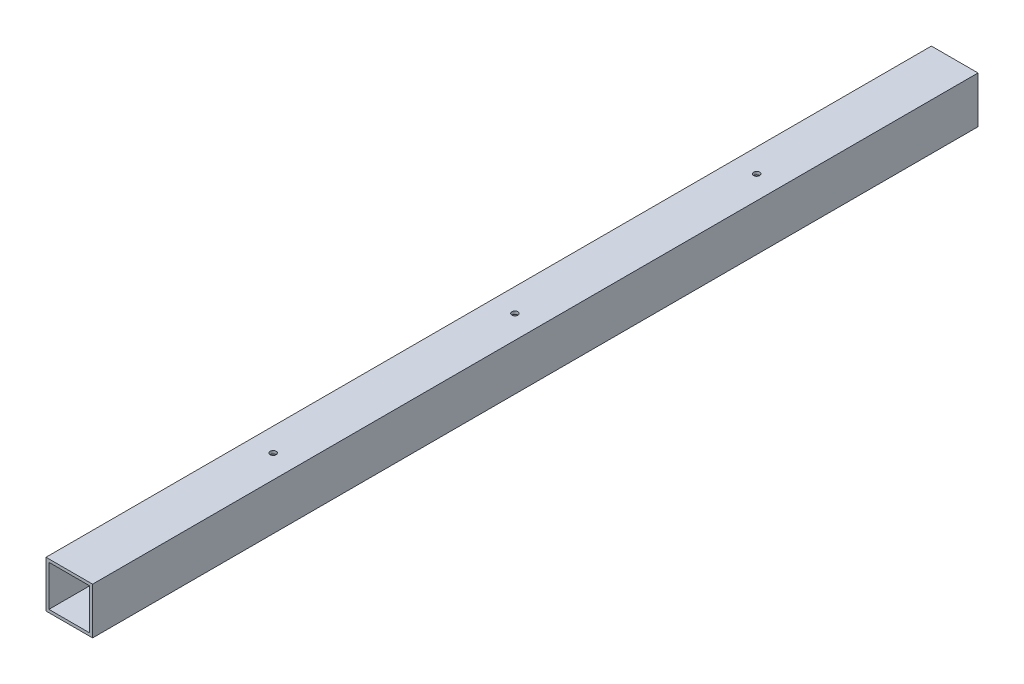
from build123d import *

# Parameters (mm, degrees)
SKETCH1_W           = 50.8
SKETCH1_H           = 50.8
SKETCH1_W_2         = 44.45
SKETCH1_H_2         = 44.45
BOSS_EXTRUDE1_DEPTH = 965.2
SKETCH2_R           = 3.302
CUT_EXTRUDE1_DEPTH  = 51.8


with BuildPart() as part:
    # Sketch1 → Boss-Extrude1 (new body)
    with BuildSketch(Plane.XY):
        with Locations((0, 25.4)):
            Rectangle(SKETCH1_W, SKETCH1_H)
        with Locations((0, 25.4)):
            Rectangle(SKETCH1_W_2, SKETCH1_H_2, mode=Mode.SUBTRACT)
    extrude(amount=BOSS_EXTRUDE1_DEPTH)

    # Sketch2 → Cut-Extrude1 (cut, through all)
    with BuildSketch(Plane(origin=(0, 50.8, 0), x_dir=(1, 0, 0), z_dir=(0, 1, 0))):
        with Locations((0, -215.9)):
            Circle(SKETCH2_R)
        with Locations((0, -479.425)):
            Circle(SKETCH2_R)
        with Locations((0, -742.95)):
            Circle(SKETCH2_R)
    extrude(amount=-CUT_EXTRUDE1_DEPTH, mode=Mode.SUBTRACT)


solid = part.part
